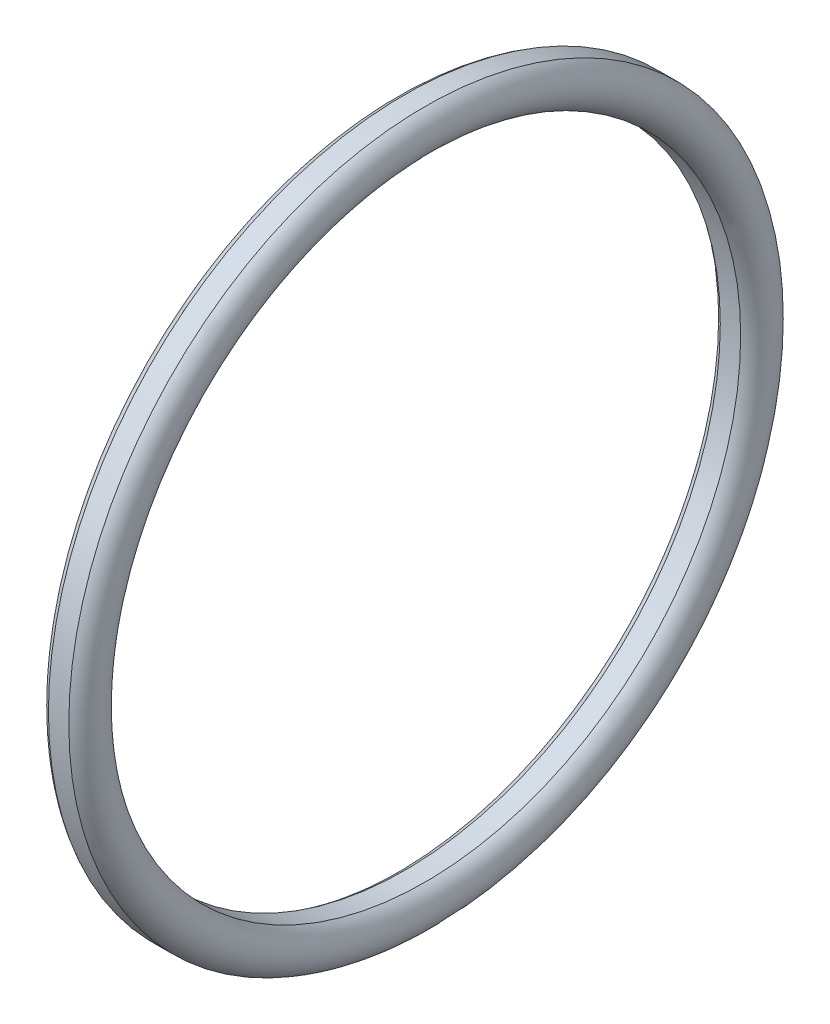
from build123d import *


with BuildPart() as part:
    # Sketch5 → Revolve4 (revolve)
    with BuildSketch(Plane.XY, mode=Mode.PRIVATE) as revolve4_sk:
        with BuildLine():
            Line((-0.335992559, 11.75), (0.335992559, 11.75))
            ThreePointArc((0.335992559, 11.75), (0.754, 11.075), (0.335992559, 10.4))
            Line((0.335992559, 10.4), (-0.335992559, 10.4))
            ThreePointArc((-0.335992559, 10.4), (-0.754, 11.075), (-0.335992559, 11.75))
        make_face()
    revolve(revolve4_sk.sketch.rotate(Axis((88.99, 0, 0), (-1, 0, 0)), 90), axis=Axis((88.99, 0, 0), (-1, 0, 0)))  # turned: the seam where the file's is


solid = part.part
